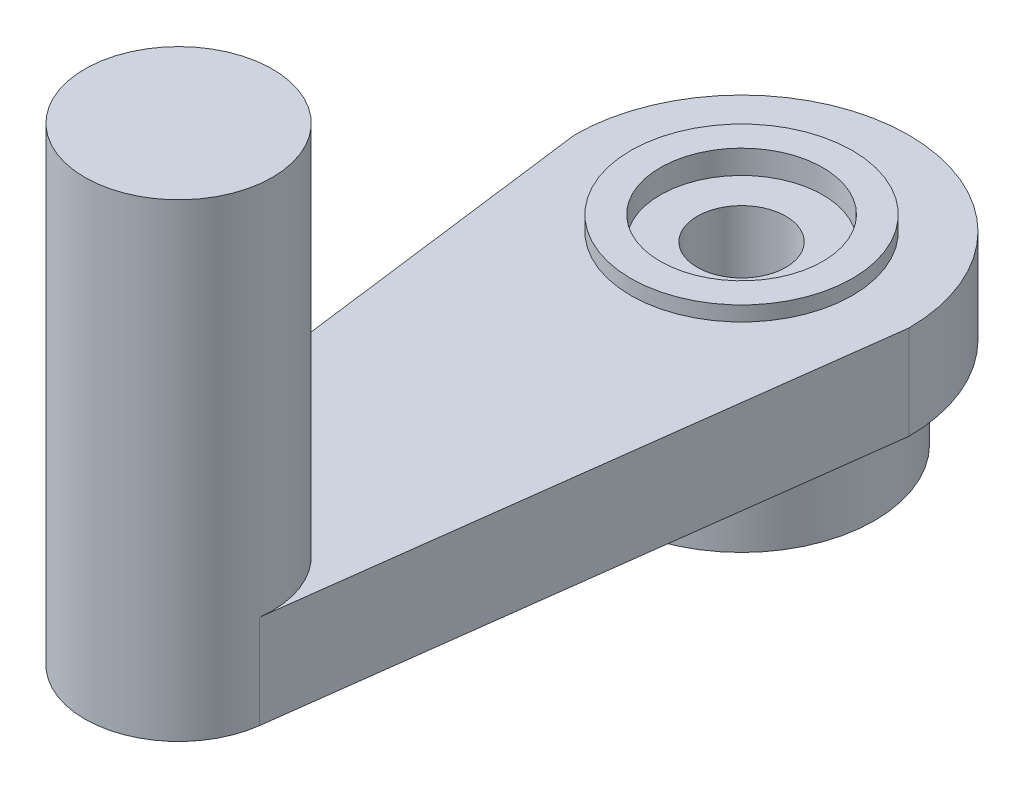
from build123d import *

# Parameters (mm, degrees)
SKETCH1_R           = 1.5
BOSS_EXTRUDE1_DEPTH = 3.175
SKETCH2_R           = 3.75
SKETCH2_R_2         = 2.75
BOSS_EXTRUDE2_DEPTH = 0.5
SKETCH3_R           = 2.75
SKETCH3_R_2         = 1.5
CUT_EXTRUDE1_DEPTH  = 0.8
SKETCH4_R           = 4.5
SKETCH4_R_2         = 2.5
BOSS_EXTRUDE3_DEPTH = 3.048
SKETCH5_R           = 2.875
CUT_EXTRUDE3_DEPTH  = 3.048
SKETCH6_R           = 3.175
BOSS_EXTRUDE4_DEPTH = 12.7
FILLET1_R           = 0.508


with BuildPart() as part:
    # Sketch1 → Boss-Extrude1 (new body)
    with BuildSketch(Plane(origin=(0, 0, 0), x_dir=(1, 0, 0), z_dir=(0, 1, 0))):
        with BuildLine():
            Line((-5.656854249, 0), (-3.148946712, -19.45590591))
            ThreePointArc((-3.148946712, -19.45590591), (0, -22.225), (3.148946712, -19.45590591))
            Line((3.148946712, -19.45590591), (5.656854249, 0))
            ThreePointArc((5.656854249, 0), (0, 5.656854249), (-5.656854249, 0))
        make_face()
        Circle(SKETCH1_R, mode=Mode.SUBTRACT)
    extrude(amount=BOSS_EXTRUDE1_DEPTH)

    # Sketch2 → Boss-Extrude2 (add)
    with BuildSketch(Plane(origin=(0, 3.175, 0), x_dir=(1, 0, 0), z_dir=(0, 1, 0))):
        Circle(SKETCH2_R)
        Circle(SKETCH2_R_2, mode=Mode.SUBTRACT)
    extrude(amount=BOSS_EXTRUDE2_DEPTH)

    # Sketch3 → Cut-Extrude1 (cut)
    with BuildSketch(Plane(origin=(0, 3.675, 0), x_dir=(1, 0, 0), z_dir=(0, 1, 0))):
        Circle(SKETCH3_R)
        Circle(SKETCH3_R_2, mode=Mode.SUBTRACT)
    extrude(amount=-CUT_EXTRUDE1_DEPTH, mode=Mode.SUBTRACT)

    # Sketch4 → Boss-Extrude3 (add)
    with BuildSketch(Plane.XZ):
        Circle(SKETCH4_R)
        Circle(SKETCH4_R_2, mode=Mode.SUBTRACT)
    extrude(amount=BOSS_EXTRUDE3_DEPTH)

    # Sketch5 → Cut-Extrude3 (cut)
    with BuildSketch(Plane.XZ.offset(3.048)):
        Circle(SKETCH5_R)
    extrude(amount=-CUT_EXTRUDE3_DEPTH, mode=Mode.SUBTRACT)

    # Sketch6 → Boss-Extrude4 (add)
    with BuildSketch(Plane(origin=(0, 3.175, 0), x_dir=(1, 0, 0), z_dir=(0, 1, 0))):
        with Locations((0, -19.05)):
            Circle(SKETCH6_R)
    extrude(amount=BOSS_EXTRUDE4_DEPTH)

    # Fillet1
    fillet1_edges = [part.edges().sort_by_distance(p)[0] for p in [
        (-2.875, -3.048, 0),
    ]]
    fillet(fillet1_edges, radius=FILLET1_R)


solid = part.part
